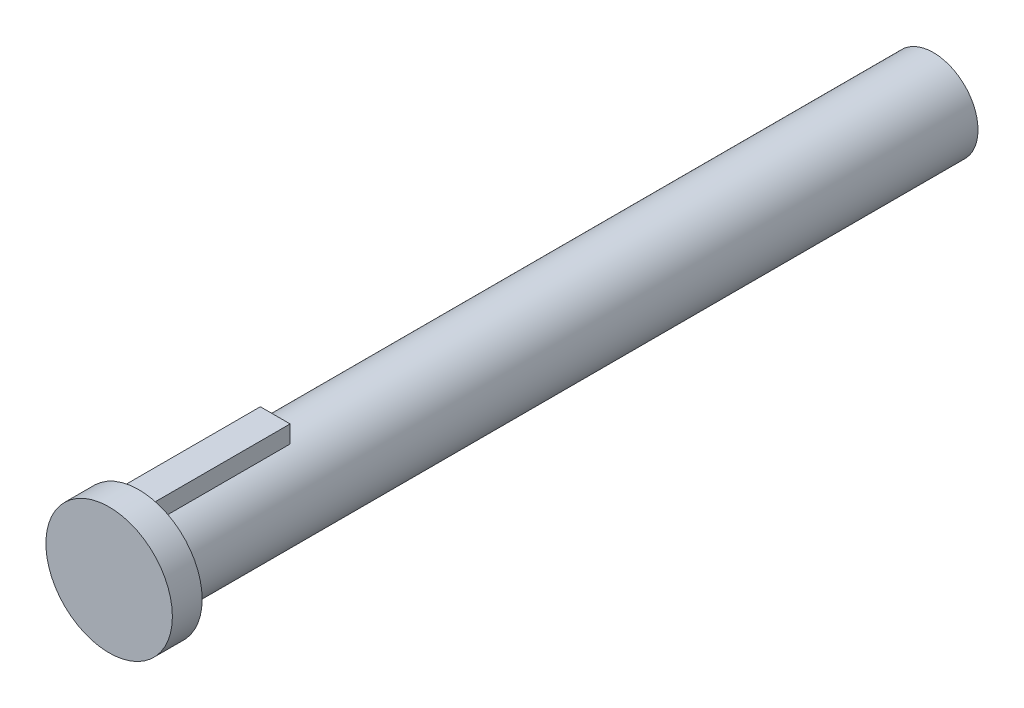
from build123d import *

# Parameters (mm, degrees)
SKETCH1_R           = 3
BOSS_EXTRUDE1_DEPTH = 53.38
SKETCH2_W           = 2
SKETCH2_H           = 1.17
BOSS_EXTRUDE2_DEPTH = 9.16
SKETCH3_R           = 4.25
BOSS_EXTRUDE3_DEPTH = 2


with BuildPart() as part:
    # Sketch1 → Boss-Extrude1 (new body)
    with BuildSketch(Plane.XY):
        Circle(SKETCH1_R)
    extrude(amount=BOSS_EXTRUDE1_DEPTH)

    # Sketch2 → Boss-Extrude2 (add)
    with BuildSketch(Plane.XY.offset(53.38)):
        with Locations((0, 3.413427125)):
            Rectangle(SKETCH2_W, SKETCH2_H)
    extrude(amount=-BOSS_EXTRUDE2_DEPTH)

    # Sketch3 → Boss-Extrude3 (add)
    with BuildSketch(Plane.XY.offset(53.38)):
        Circle(SKETCH3_R)
    extrude(amount=BOSS_EXTRUDE3_DEPTH)


solid = part.part
